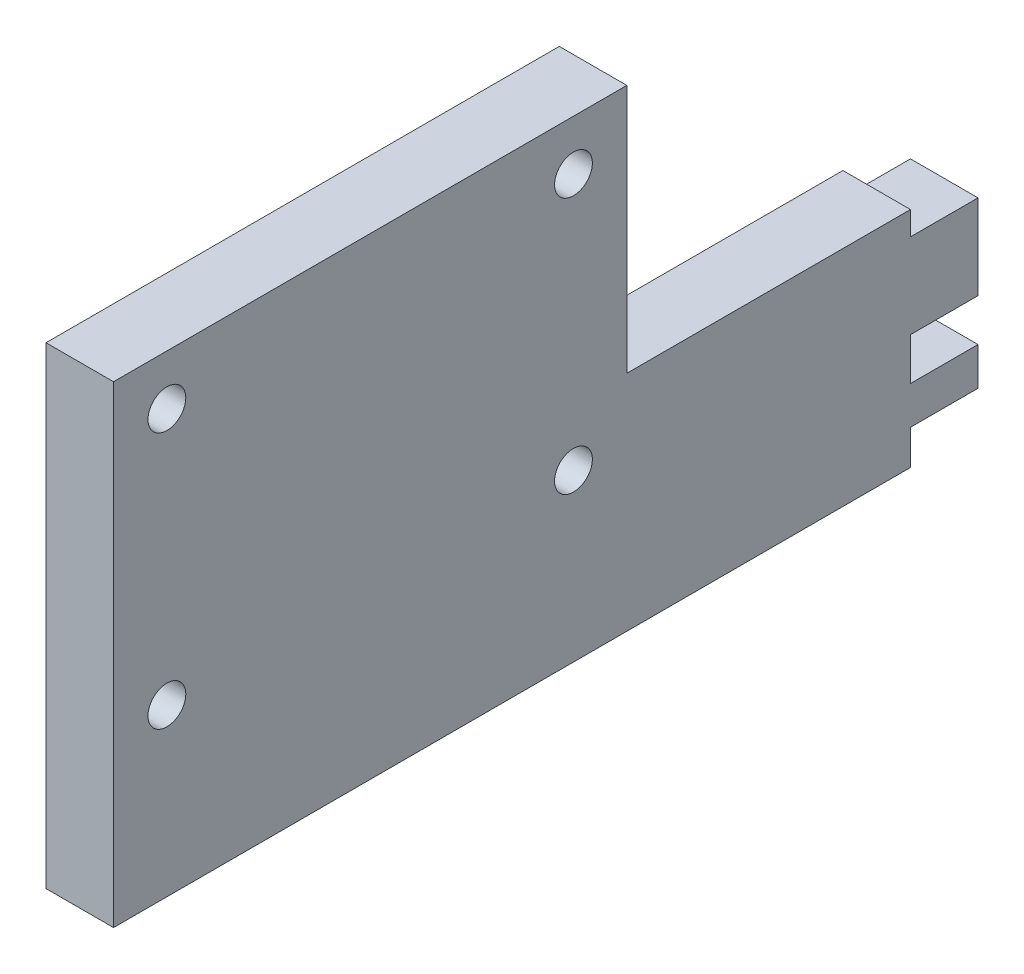
from build123d import *

# Parameters (mm, degrees)
SKETCH1_R           = 1.4
BOSS_EXTRUDE1_DEPTH = 5


with BuildPart() as part:
    # Sketch1 → Boss-Extrude1 (new body)
    with BuildSketch(Plane(origin=(0, 0, 0), x_dir=(0, 0, -1), z_dir=(1, 0, 0))):
        Polygon((0, 0), (-21, 0), (-21, 18.45912049), (-59, 18.45912049), (-59, 3.45912049), (-59, -16.54087951), (0, -16.54087951), (0, -13.963518408), (5, -13.963518408), (5, -11.15648618), (0, -11.15648618), (0, -8.024983971), (5, -8.024983971), (5, -1.752077979), (0, -1.752077979), align=None)
        with Locations((-24.95, -4.24087951)):
            Circle(SKETCH1_R, mode=Mode.SUBTRACT)
        with Locations((-55.05, -4.24087951)):
            Circle(SKETCH1_R, mode=Mode.SUBTRACT)
        with Locations((-24.95, 14.75912049)):
            Circle(SKETCH1_R, mode=Mode.SUBTRACT)
        with Locations((-55.05, 14.75912049)):
            Circle(SKETCH1_R, mode=Mode.SUBTRACT)
    extrude(amount=BOSS_EXTRUDE1_DEPTH)


solid = part.part
